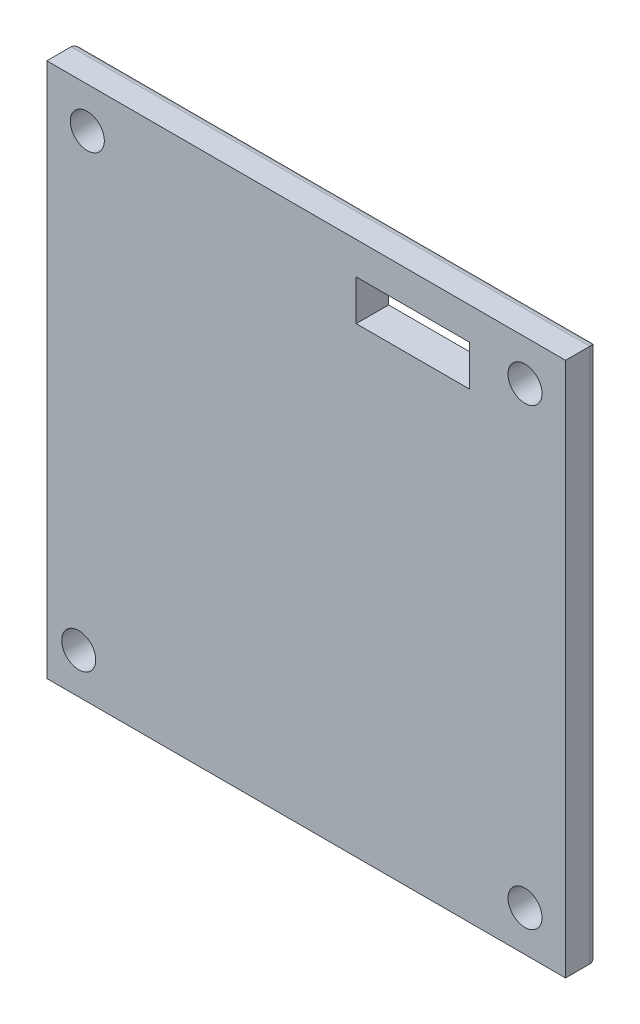
from build123d import *

# Parameters (mm, degrees)
SKETCH1_R           = 21
BOSS_EXTRUDE1_DEPTH = 8
SKETCH2_R           = 2
CUT_EXTRUDE1_DEPTH  = 10
SKETCH4_R           = 1.1
CUT_EXTRUDE2_DEPTH  = 10
SKETCH5_R           = 1.1
CUT_EXTRUDE3_DEPTH  = 10
SKETCH11_W          = 64
SKETCH11_H          = 66
BOSS_EXTRUDE3_DEPTH = 4
FILLET12_R          = 1
SKETCH16_W          = 14
SKETCH16_H          = 5
CUT_EXTRUDE7_DEPTH  = 22
SKETCH17_R          = 21
CUT_EXTRUDE9_DEPTH  = 8
SKETCH18_R          = 2.1
CUT_EXTRUDE10_DEPTH = 12
SKETCH19_R          = 4
BOSS_EXTRUDE4_DEPTH = 20


with BuildPart() as part:
    # Sketch1 → Boss-Extrude1 (new body)
    with BuildSketch(Plane.XY):
        Circle(SKETCH1_R)
    extrude(amount=BOSS_EXTRUDE1_DEPTH)

    # Sketch2 → Cut-Extrude1 (cut)
    with BuildSketch(Plane(origin=(0, 0, 0), x_dir=(-1, 0, 0), z_dir=(0, 0, -1))):
        Circle(SKETCH2_R)
    extrude(amount=-CUT_EXTRUDE1_DEPTH, mode=Mode.SUBTRACT)

    # Sketch4 → Cut-Extrude2 (cut)
    with BuildSketch(Plane(origin=(0, 0, 0), x_dir=(-1, 0, 0), z_dir=(0, 0, -1))):
        with Locations((16, 0)):
            Circle(SKETCH4_R)
    extrude(amount=-CUT_EXTRUDE2_DEPTH, mode=Mode.SUBTRACT)

    # Sketch5 → Cut-Extrude3 (cut)
    with BuildSketch(Plane(origin=(0, 0, 0), x_dir=(-1, 0, 0), z_dir=(0, 0, -1))):
        with Locations((-16, 0)):
            Circle(SKETCH5_R)
    extrude(amount=-CUT_EXTRUDE3_DEPTH, mode=Mode.SUBTRACT)

    # Sketch11 → Boss-Extrude3 (add)
    with BuildSketch(Plane(origin=(0, 0, 0), x_dir=(-1, 0, 0), z_dir=(0, 0, -1))):
        Rectangle(SKETCH11_W, SKETCH11_H)
    extrude(amount=BOSS_EXTRUDE3_DEPTH)

    # Fillet12
    fillet12_edges = [part.edges().sort_by_distance(p)[0] for p in [
        (-32, 0, -4),
        (0, 33, -4),
        (32, 0, -4),
        (0, -33, -4),
    ]]
    fillet(fillet12_edges, radius=FILLET12_R)

    # Sketch16 → Cut-Extrude7 (cut)
    with BuildSketch(Plane(origin=(0, 0, -4), x_dir=(-1, 0, 0), z_dir=(0, 0, -1))):
        with Locations((-13.170947401, 26.5)):
            Rectangle(SKETCH16_W, SKETCH16_H)
    extrude(amount=-CUT_EXTRUDE7_DEPTH, mode=Mode.SUBTRACT)

    # Sketch17 → Cut-Extrude9 (cut)
    with BuildSketch(Plane.XY.offset(8)):
        Circle(SKETCH17_R)
    extrude(amount=-CUT_EXTRUDE9_DEPTH, mode=Mode.SUBTRACT)

    # Sketch18 → Cut-Extrude10 (cut)
    with BuildSketch(Plane(origin=(0, 0, -4), x_dir=(-1, 0, 0), z_dir=(0, 0, -1))):
        with Locations((-27, 28)):
            Circle(SKETCH18_R)
        with Locations((-27, -28)):
            Circle(SKETCH18_R)
        with Locations((28.056628896, -28)):
            Circle(SKETCH18_R)
        with Locations((27, 28)):
            Circle(SKETCH18_R)
    extrude(amount=-CUT_EXTRUDE10_DEPTH, mode=Mode.SUBTRACT)

    # Sketch19 → Boss-Extrude4 (add)
    with BuildSketch(Plane(origin=(0, 0, -4), x_dir=(-1, 0, 0), z_dir=(0, 0, -1))):
        Circle(SKETCH19_R)
    extrude(amount=BOSS_EXTRUDE4_DEPTH)

    # Sketch20 → Revolve1 (revolve)
    with BuildSketch(Plane(origin=(0, 0, 0), x_dir=(1, 0, 0), z_dir=(0, 1, 0))):
        with BuildLine():
            Line((0, 24), (-4, 24))
            ThreePointArc((-4, 24), (-2.828427125, 26.828427125), (0, 28))
            Line((0, 28), (0, 24))
        make_face()
    revolve(axis=Axis((0, 0, -24), (0, 0, -1)))


solid = part.part
